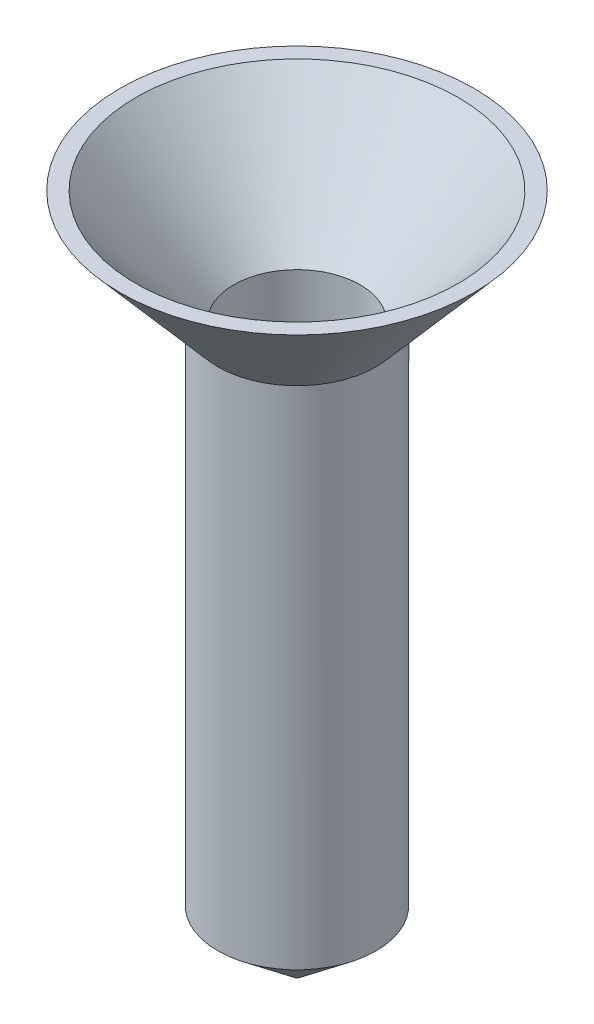
from build123d import *

# Parameters (mm, degrees)
SKETCH2_R           = 31.75
SKETCH2_R_2         = 25.4
BOSS_EXTRUDE1_DEPTH = 254
SKETCH5_R           = 46.805948237
CUT_EXTRUDE1_DEPTH  = 50.8


with BuildPart() as part:
    # Sketch2 → Boss-Extrude1 (new body)
    with BuildSketch(Plane(origin=(0, 0, 0), x_dir=(1, 0, 0), z_dir=(0, 1, 0))):
        Circle(SKETCH2_R)
        Circle(SKETCH2_R_2, mode=Mode.SUBTRACT)
    extrude(amount=-BOSS_EXTRUDE1_DEPTH)

    # Sketch4 → Revolve1 (revolve)
    with BuildSketch(Plane(origin=(0, 0, 0), x_dir=(0, 0, -1), z_dir=(1, 0, 0))):
        Polygon((31.75, 0), (71.093054088, 45.488426276), (64.743054088, 45.488426276), (25.4, 0), align=None)
    revolve(axis=Axis((0, 0, 0), (0, 1, 0)))

    # Sketch5 → Cut-Extrude1 (cut)
    with BuildSketch(Plane.XZ.offset(254)):
        Circle(SKETCH5_R)
    extrude(amount=-CUT_EXTRUDE1_DEPTH, mode=Mode.SUBTRACT)

    # Sketch6 → Revolve2 (revolve)
    with BuildSketch(Plane(origin=(0, 0, 0), x_dir=(0, 0, -1), z_dir=(1, 0, 0))):
        Polygon((-31.75, -203.2), (-25.4, -203.2), (-0.675857916, -225.226857467), (-1.351715832, -227.518627335), align=None)
    revolve(axis=Axis((0, -254, 0), (0, 1, 0)))


solid = part.part
